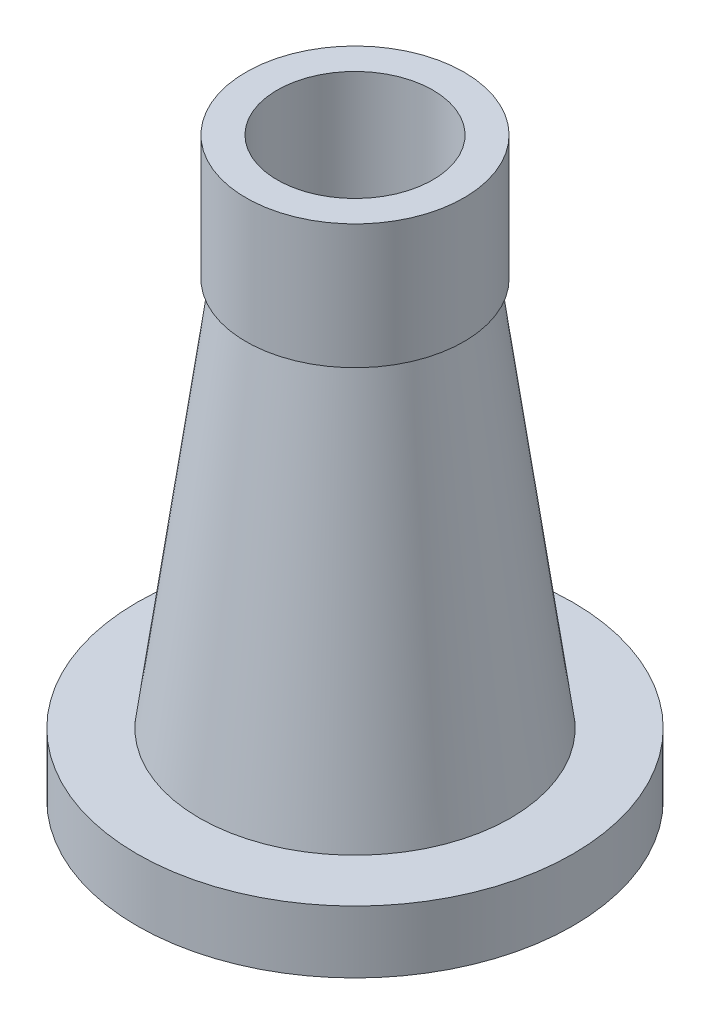
from build123d import *


with BuildPart() as part:
    # Sketch1 → Revolve1 (revolve)
    with BuildSketch(Plane.XY):
        Polygon((70, 0), (70, 20), (50, 20), (33, 145), (35, 145), (35, 185), (25, 185), (25, 129.61723322), (42.219943718, 3), (50, 3), (50, 0), align=None)
    revolve(axis=Axis((0, 0, 0), (0, 1, 0)))


solid = part.part
